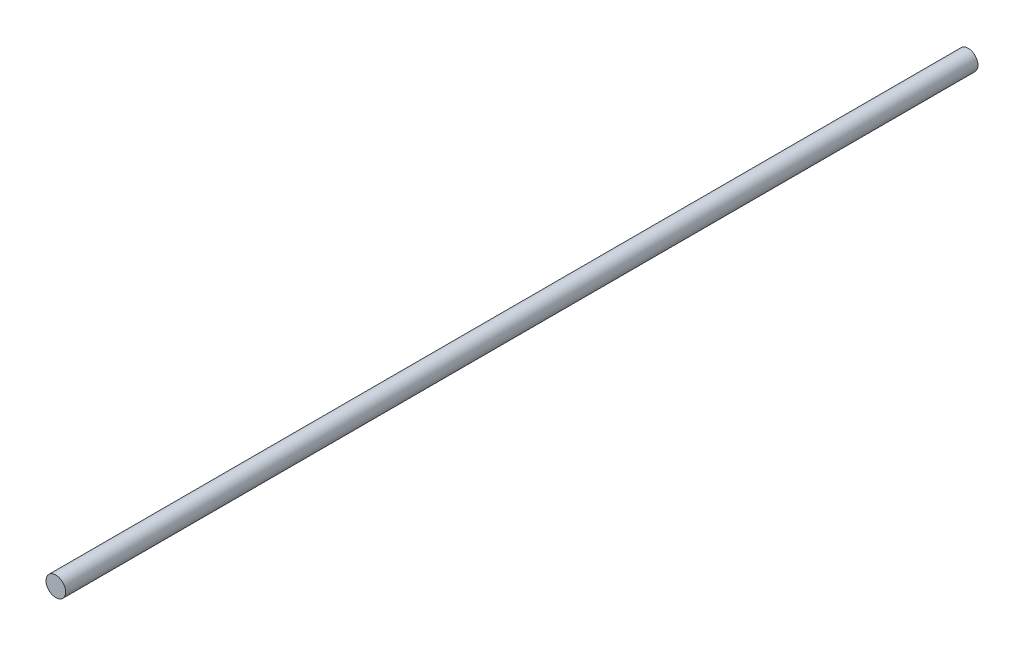
from build123d import *

# Parameters (mm, degrees)
SKETCH1_R           = 3.96875
BOSS_EXTRUDE1_DEPTH = 368.3


with BuildPart() as part:
    # Sketch1 → Boss-Extrude1 (new body)
    with BuildSketch(Plane.XY):
        Circle(SKETCH1_R)
    extrude(amount=BOSS_EXTRUDE1_DEPTH)


solid = part.part
